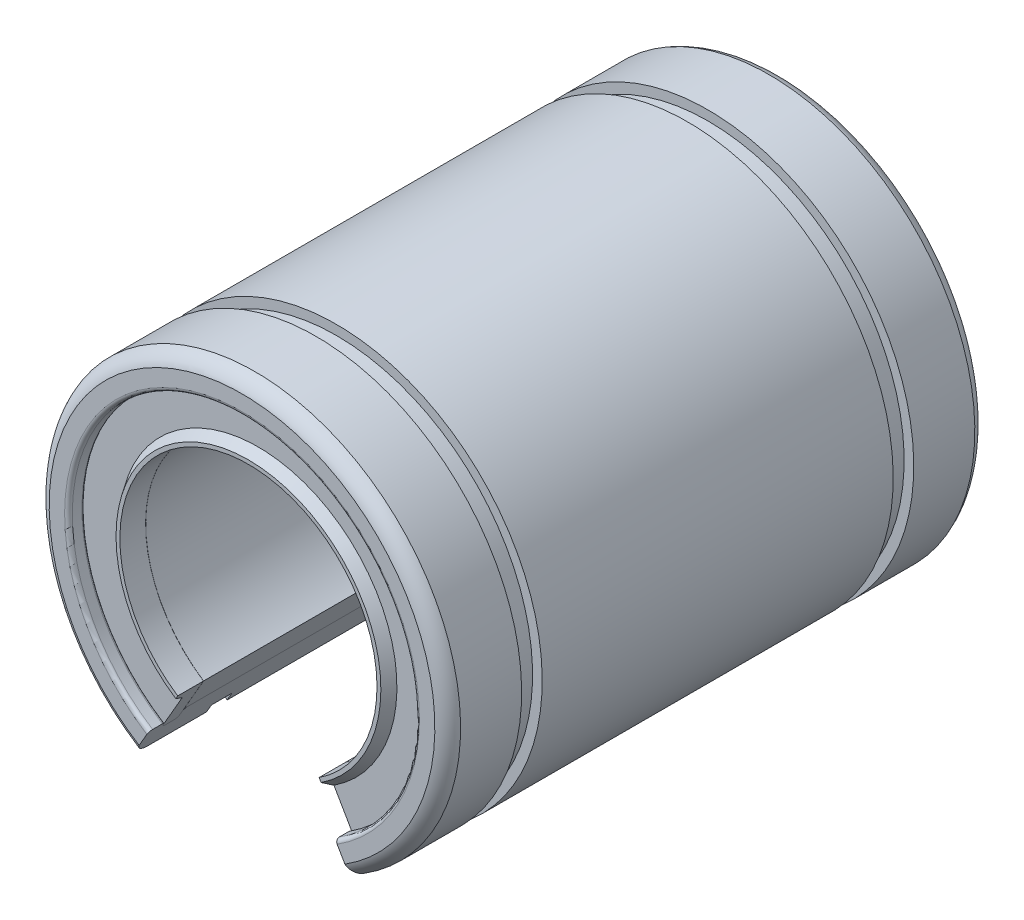
from build123d import *

# Parameters (mm, degrees)
SKETCH_1_W               = 36.98
SKETCH_1_H               = 3
CUT_EXTRUDE_1_DEPTH      = 31.870698081
CUT_EXTRUDE_1_DEPTH_BACK = 31.870698081


with BuildPart() as part:
    # Эскиз1 → Повернуть1 (revolve)
    with BuildSketch(Plane(origin=(0, 0, 0), x_dir=(0, 0, -1), z_dir=(1, 0, 0))):
        with BuildLine():
            Line((-19.75, 10.8), (-20.5, 10.3))
            Line((-20.5, 10.3), (-20.5, 10))
            Line((-20.5, 10), (-18.5, 10))
            Line((-18.5, 10), (-18.5, 13.7))
            ThreePointArc((-18.5, 13.7), (-18.587867966, 13.912132034), (-18.8, 14))
            Line((-18.8, 14), (-19.45, 14))
            ThreePointArc((-19.45, 14), (-19.662132034, 13.912132034), (-19.75, 13.7))
            Line((-19.75, 13.7), (-19.75, 10.8))
        make_face()
        with Locations((0, 11.5)):
            Rectangle(SKETCH_1_W, SKETCH_1_H)
        with BuildLine():
            Line((18.5, 10), (20.5, 10))
            Line((20.5, 10), (20.5, 10.3))
            Line((20.5, 10.3), (19.75, 10.8))
            Line((19.75, 10.8), (19.75, 13.7))
            ThreePointArc((19.75, 13.7), (19.662132034, 13.912132034), (19.45, 14))
            Line((19.45, 14), (18.8, 14))
            ThreePointArc((18.8, 14), (18.587867966, 13.912132034), (18.5, 13.7))
            Line((18.5, 13.7), (18.5, 10))
        make_face()
    revolve(axis=Axis((0, 0, 43.343199199), (0, 0, -1)))


with BuildPart() as body_2:
    # Эскиз1<3> → Повернуть2 (revolve)
    with BuildSketch(Plane(origin=(0, 0, 0), x_dir=(0, 0, -1), z_dir=(1, 0, 0))):
        with BuildLine():
            Line((-15.25, 16), (-20, 16))
            ThreePointArc((-20, 16), (-20.625245825, 15.625245825), (-21, 15))
            Line((-21, 15), (-21, 13.8))
            ThreePointArc((-21, 13.8), (-20.912132034, 13.587867966), (-20.7, 13.5))
            Line((-20.7, 13.5), (-19.95, 13.5))
            ThreePointArc((-19.95, 13.5), (-19.808578644, 13.558578644), (-19.75, 13.7))
            ThreePointArc((-19.75, 13.7), (-19.662132034, 13.912132034), (-19.45, 14))
            Line((-19.45, 14), (-18.8, 14))
            ThreePointArc((-18.8, 14), (-18.587867966, 13.912132034), (-18.5, 13.7))
            Line((-18.5, 13.7), (-18.5, 13.3))
            ThreePointArc((-18.5, 13.3), (-18.412132034, 13.087867966), (-18.2, 13))
            Line((-18.2, 13), (18.2, 13))
            ThreePointArc((18.2, 13), (18.412132034, 13.087867966), (18.5, 13.3))
            Line((18.5, 13.3), (18.5, 13.7))
            ThreePointArc((18.5, 13.7), (18.587867966, 13.912132034), (18.8, 14))
            Line((18.8, 14), (19.45, 14))
            ThreePointArc((19.45, 14), (19.662132034, 13.912132034), (19.75, 13.7))
            ThreePointArc((19.75, 13.7), (19.808578644, 13.558578644), (19.95, 13.5))
            Line((19.95, 13.5), (20.7, 13.5))
            ThreePointArc((20.7, 13.5), (20.912132034, 13.587867966), (21, 13.8))
            Line((21, 13.8), (21, 15))
            ThreePointArc((21, 15), (20.625245825, 15.625245825), (20, 16))
            Line((20, 16), (15.25, 16))
            Line((15.25, 16), (15.25, 15.25))
            Line((15.25, 15.25), (13.65, 15.25))
            Line((13.65, 15.25), (13.65, 16))
            Line((13.65, 16), (-13.65, 16))
            Line((-13.65, 16), (-13.65, 15.25))
            Line((-13.65, 15.25), (-15.25, 15.25))
            Line((-15.25, 15.25), (-15.25, 16))
        make_face()
    revolve(axis=Axis((0, 0, 43.343199199), (0, 0, -1)))


with BuildPart() as cut_extrude_1_tool:
    # Эскиз2 → Вырез-Вытянуть1 (new, two sides: drawn at the far end of the back side and taken through both)
    with BuildSketch(Plane.XY.offset(-CUT_EXTRUDE_1_DEPTH_BACK)):
        Polygon((0, 1.174632897), (9.915778927, -16), (-9.915778927, -16), align=None)
    extrude(amount=CUT_EXTRUDE_1_DEPTH + CUT_EXTRUDE_1_DEPTH_BACK)


with BuildPart() as part_1:
    add(part.part)

    # Вырез-Вытянуть1: cut by cut_extrude_1_tool
    add(cut_extrude_1_tool.part, mode=Mode.SUBTRACT)


with BuildPart() as body_2_1:
    add(body_2.part)

    # Вырез-Вытянуть1: cut by cut_extrude_1_tool
    add(cut_extrude_1_tool.part, mode=Mode.SUBTRACT)


solid = Compound([part_1.part, body_2_1.part])
